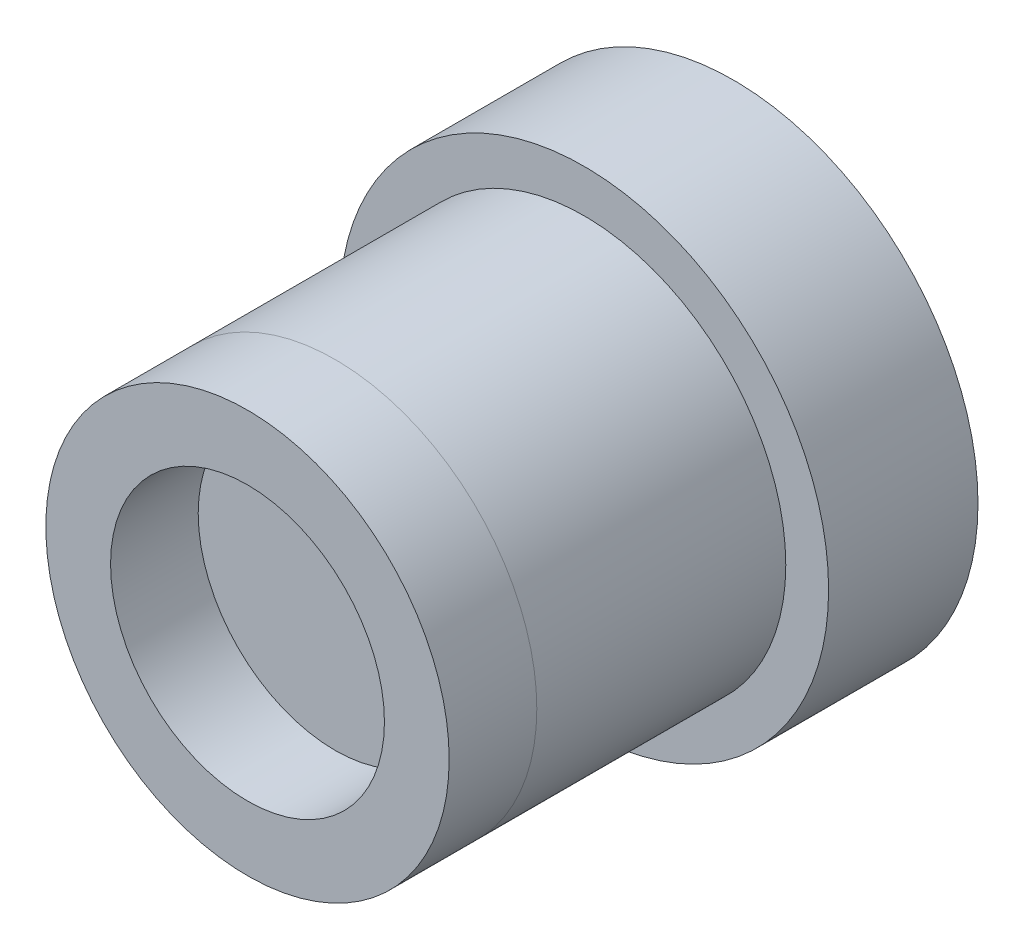
from build123d import *

# Parameters (mm, degrees)
SKETCH1_R           = 4.91
BOSS_EXTRUDE1_DEPTH = 8
SKETCH2_R           = 4.05
SKETCH2_R_2         = 2.75
BOSS_EXTRUDE2_DEPTH = 1.76
SKETCH3_R           = 4.91
SKETCH3_R_2         = 4.05
CUT_EXTRUDE1_DEPTH  = 5


with BuildPart() as part:
    # Sketch1 → Boss-Extrude1 (new body)
    with BuildSketch(Plane.XY):
        Circle(SKETCH1_R)
    extrude(amount=BOSS_EXTRUDE1_DEPTH)

    # Sketch3 → Cut-Extrude1 (cut)
    with BuildSketch(Plane.XY.offset(8)):
        Circle(SKETCH3_R)
        Circle(SKETCH3_R_2, mode=Mode.SUBTRACT)
    extrude(amount=-CUT_EXTRUDE1_DEPTH, mode=Mode.SUBTRACT)


with BuildPart() as body_2:
    # Sketch2 → Boss-Extrude2 (new body)
    with BuildSketch(Plane.XY.offset(8)):
        Circle(SKETCH2_R)
        Circle(SKETCH2_R_2, mode=Mode.SUBTRACT)
    extrude(amount=BOSS_EXTRUDE2_DEPTH)


solid = Compound([part.part, body_2.part])
